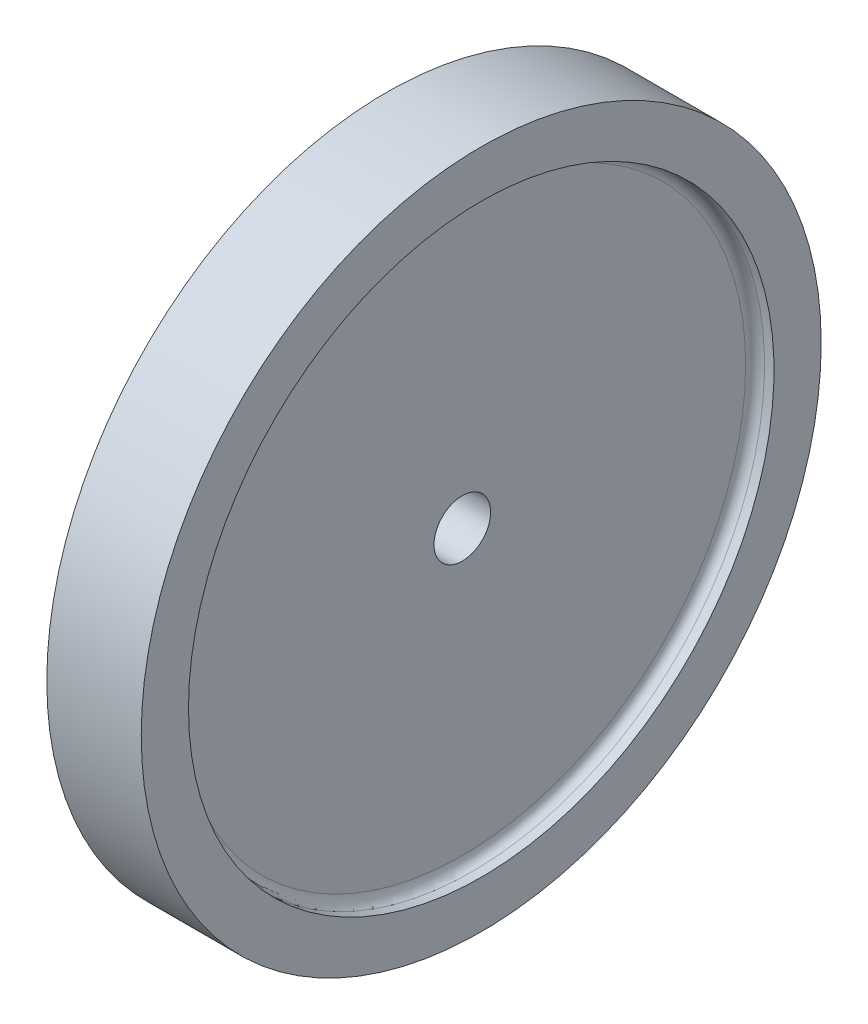
from build123d import *

# Parameters (mm, degrees)
ESQUISSE2_R             = 3
ENL_V_MAT_EXTRU_2_DEPTH = 9
CONG_1_R                = 1


with BuildPart() as part:
    # Esquisse1 → Révolution1 (revolve)
    with BuildSketch(Plane.XY):
        Polygon((-3, 31), (-5, 31), (-5, 36), (5, 36), (5, 31), (3, 31), (3, 0), (-3, 0), align=None)
    revolve(axis=Axis((-3, 0, 0), (1, 0, 0)))

    # Esquisse2 → Enlèv. mat.-Extru.2 (cut, through all)
    with BuildSketch(Plane(origin=(3, 0, 0), x_dir=(0, 0, -1), z_dir=(1, 0, 0))):
        Circle(ESQUISSE2_R)
    extrude(amount=-ENL_V_MAT_EXTRU_2_DEPTH, mode=Mode.SUBTRACT)

    # Congé1
    cong_1_edges = [part.edges().sort_by_distance(p)[0] for p in [
        (-3, -31, 0),
        (3, -31, 0),
    ]]
    fillet(cong_1_edges, radius=CONG_1_R)


solid = part.part
